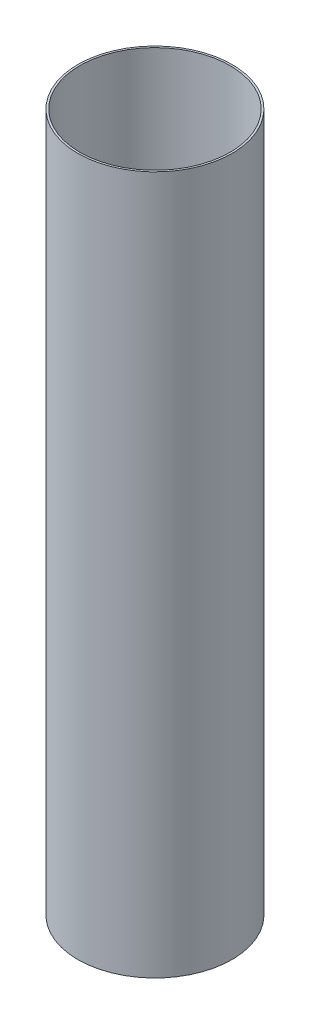
from build123d import *

# Parameters (mm, degrees)
SKETCH1_R           = 100.965
SKETCH1_R_2         = 98.425
BOSS_EXTRUDE1_DEPTH = 914.4


with BuildPart() as part:
    # Sketch1 → Boss-Extrude1 (new body)
    with BuildSketch(Plane(origin=(0, 0, 0), x_dir=(1, 0, 0), z_dir=(0, 1, 0))):
        Circle(SKETCH1_R)
        Circle(SKETCH1_R_2, mode=Mode.SUBTRACT)
    extrude(amount=BOSS_EXTRUDE1_DEPTH)


solid = part.part
